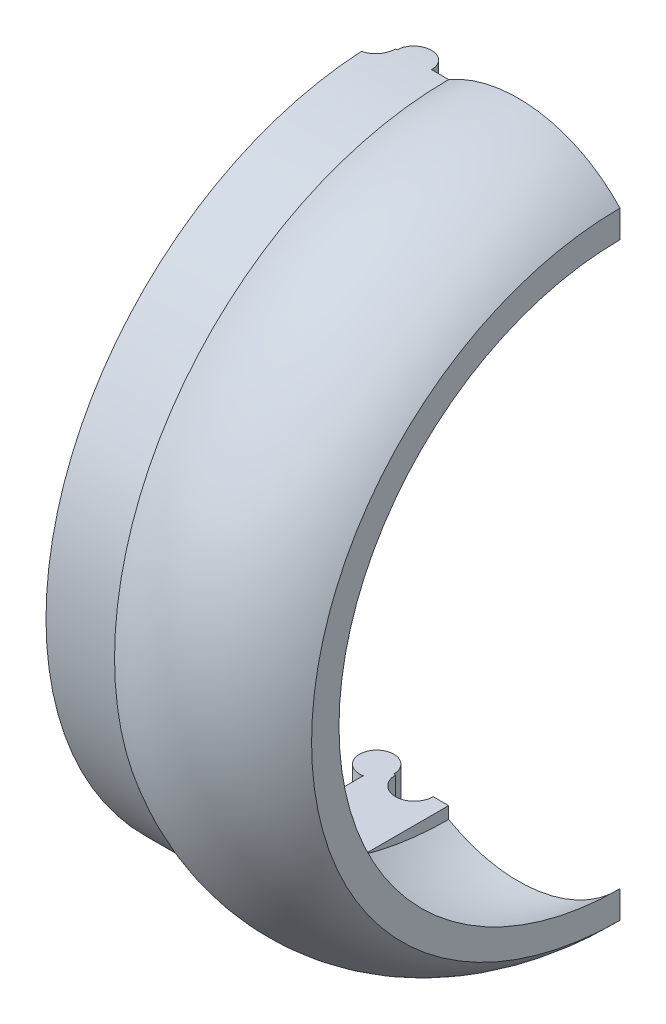
from build123d import *

# Parameters (mm, degrees)
REVOLVE1_ANGLE           = 180
BOSS_EXTRUDE1_DEPTH      = 20
BOSS_EXTRUDE2_REACH      = 228.274
BOSS_EXTRUDE2_END_RADIUS = 97.5
SKETCH5_R                = 5
CUT_EXTRUDE1_REACH       = 228.274
CUT_EXTRUDE1_END_RADIUS  = 97.5
SKETCH6_R                = 5.5
BOSS_EXTRUDE3_REACH      = 228.274
BOSS_EXTRUDE3_END_RADIUS = 97.5
SKETCH8_R                = 5
CUT_EXTRUDE2_REACH       = 228.274
CUT_EXTRUDE2_END_RADIUS  = 97.5
SKETCH10_R               = 5.5


with BuildPart() as part:
    # Sketch1 → Revolve1 (revolve)
    with BuildSketch(Plane.XY):
        with BuildLine():
            Line((0, 89.5), (20, 89.5))
            ThreePointArc((20, 89.5), (46.3125, 94.5), (70, 82))
            Line((70, 82), (70, 90))
            ThreePointArc((70, 90), (46.3125, 102.5), (20, 97.5))
            Line((20, 97.5), (0, 97.5))
            Line((0, 97.5), (0, 89.5))
        make_face()
    revolve(axis=Axis((0, 0, 0), (1, 0, 0)), revolution_arc=REVOLVE1_ANGLE)

    # Sketch3 → Boss-Extrude1 (add)
    with BuildSketch(Plane.ZY):
        with BuildLine():
            ThreePointArc((24.784067463, 86), (12.514991011, 88.620680431), (0, 89.5))
            Line((0, 89.5), (0, 86))
            Line((0, 86), (24.784067463, 86))
        make_face()
        with BuildLine():
            Line((0, -86), (0, -89.5))
            ThreePointArc((0, -89.5), (12.514991011, -88.620680431), (24.784067463, -86))
            Line((24.784067463, -86), (0, -86))
        make_face()
    extrude(amount=-BOSS_EXTRUDE1_DEPTH)

    # Boss-Extrude2: up to this cylinder (the profile starts inside it)
    boss_extrude2_end = Plane(origin=(10, 0, 0), z_dir=(-1, 0, 0)) * Cylinder(BOSS_EXTRUDE2_END_RADIUS, 652.548, mode=Mode.PRIVATE)
    # Sketch5 → Boss-Extrude2 (add, up to the surface)
    with BuildSketch(Plane.XZ.offset(-86), mode=Mode.PRIVATE) as boss_extrude2_sk1:
        with Locations((10, 0)):
            Circle(SKETCH5_R)
    boss_extrude2_tool1 = extrude(boss_extrude2_sk1.sketch, amount=-BOSS_EXTRUDE2_REACH, mode=Mode.PRIVATE) & boss_extrude2_end
    add(boss_extrude2_tool1.solids().sort_by_distance((10, 86, 0))[0])

    # Cut-Extrude1: up to this cylinder (the profile starts inside it)
    cut_extrude1_end = Plane(origin=(10, 0, 0), z_dir=(-1, 0, 0)) * Cylinder(CUT_EXTRUDE1_END_RADIUS, 652.548, mode=Mode.PRIVATE)
    # Sketch6 → Cut-Extrude1 (cut, up to the surface)
    with BuildSketch(Plane(origin=(0, -86, 0), x_dir=(1, 0, 0), z_dir=(0, 1, 0)), mode=Mode.PRIVATE) as cut_extrude1_sk1:
        with Locations((10, 0)):
            Circle(SKETCH6_R)
    cut_extrude1_tool1 = extrude(cut_extrude1_sk1.sketch, amount=-CUT_EXTRUDE1_REACH, mode=Mode.PRIVATE) & cut_extrude1_end
    add(cut_extrude1_tool1.solids().sort_by_distance((10, -86, 0))[0], mode=Mode.SUBTRACT)

    # Boss-Extrude3: up to this cylinder (the profile starts inside it)
    boss_extrude3_end = Plane(origin=(-1, 0, 0), z_dir=(-1, 0, 0)) * Cylinder(BOSS_EXTRUDE3_END_RADIUS, 652.548, mode=Mode.PRIVATE)
    # Sketch8 → Boss-Extrude3 (add, up to the surface)
    with BuildSketch(Plane(origin=(0, -86, 0), x_dir=(1, 0, 0), z_dir=(0, 1, 0)), mode=Mode.PRIVATE) as boss_extrude3_sk1:
        with Locations((-1, 0)):
            Circle(SKETCH8_R)
    boss_extrude3_tool1 = extrude(boss_extrude3_sk1.sketch, amount=-BOSS_EXTRUDE3_REACH, mode=Mode.PRIVATE) & boss_extrude3_end
    add(boss_extrude3_tool1.solids().sort_by_distance((-1, -86, 0))[0])

    # Cut-Extrude2: up to this cylinder (the profile starts inside it)
    cut_extrude2_end = Plane(origin=(-1, 0, 0), z_dir=(-1, 0, 0)) * Cylinder(CUT_EXTRUDE2_END_RADIUS, 652.548, mode=Mode.PRIVATE)
    # Sketch10 → Cut-Extrude2 (cut, up to the surface)
    with BuildSketch(Plane.XZ.offset(-86), mode=Mode.PRIVATE) as cut_extrude2_sk1:
        with Locations((-1, 0)):
            Circle(SKETCH10_R)
    cut_extrude2_tool1 = extrude(cut_extrude2_sk1.sketch, amount=-CUT_EXTRUDE2_REACH, mode=Mode.PRIVATE) & cut_extrude2_end
    add(cut_extrude2_tool1.solids().sort_by_distance((-1, 86, 0))[0], mode=Mode.SUBTRACT)


solid = part.part
